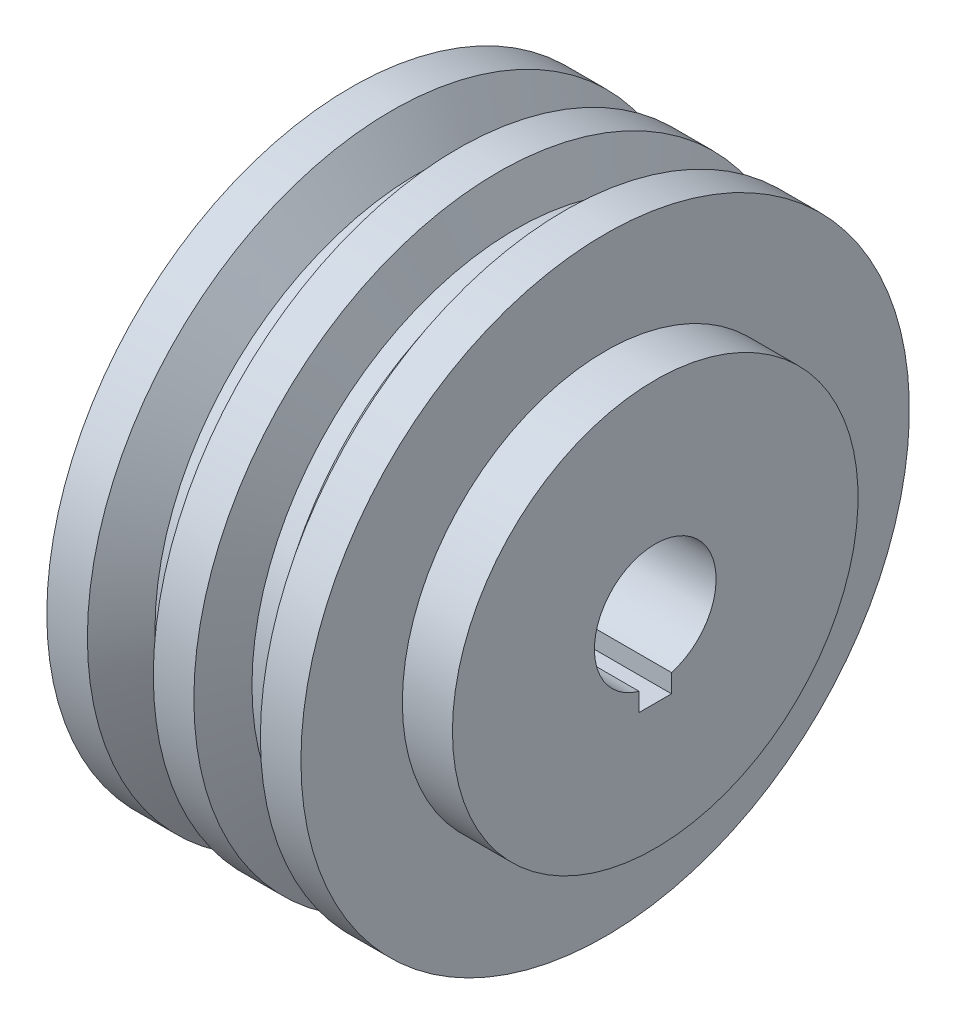
from build123d import *

# Parameters (mm, degrees)
SKETCH2_W          = 8
SKETCH2_H          = 8
CUT_EXTRUDE1_DEPTH = 76


with BuildPart() as part:
    # Sketch1 → Revolve1 (revolve)
    with BuildSketch(Plane.XY):
        Polygon((75, -15), (10, -15), (0, -70), (0, -75), (10, -75), (16.659953574, -65), (21.299953574, -65), (26.250205442, -75), (36.250205442, -75), (40.571282755, -65), (45.211282755, -65), (52.646188266, -75), (62.646188266, -75), (62.646188266, -50), (75, -50), align=None)
    revolve(axis=Axis((0, 0, 0), (1, 0, 0)))

    # Sketch2 → Cut-Extrude1 (cut, through all)
    with BuildSketch(Plane(origin=(75, 0, 0), x_dir=(0, 0, -1), z_dir=(1, 0, 0))):
        with Locations((0, -15)):
            Rectangle(SKETCH2_W, SKETCH2_H)
    extrude(amount=-CUT_EXTRUDE1_DEPTH, mode=Mode.SUBTRACT)


solid = part.part
